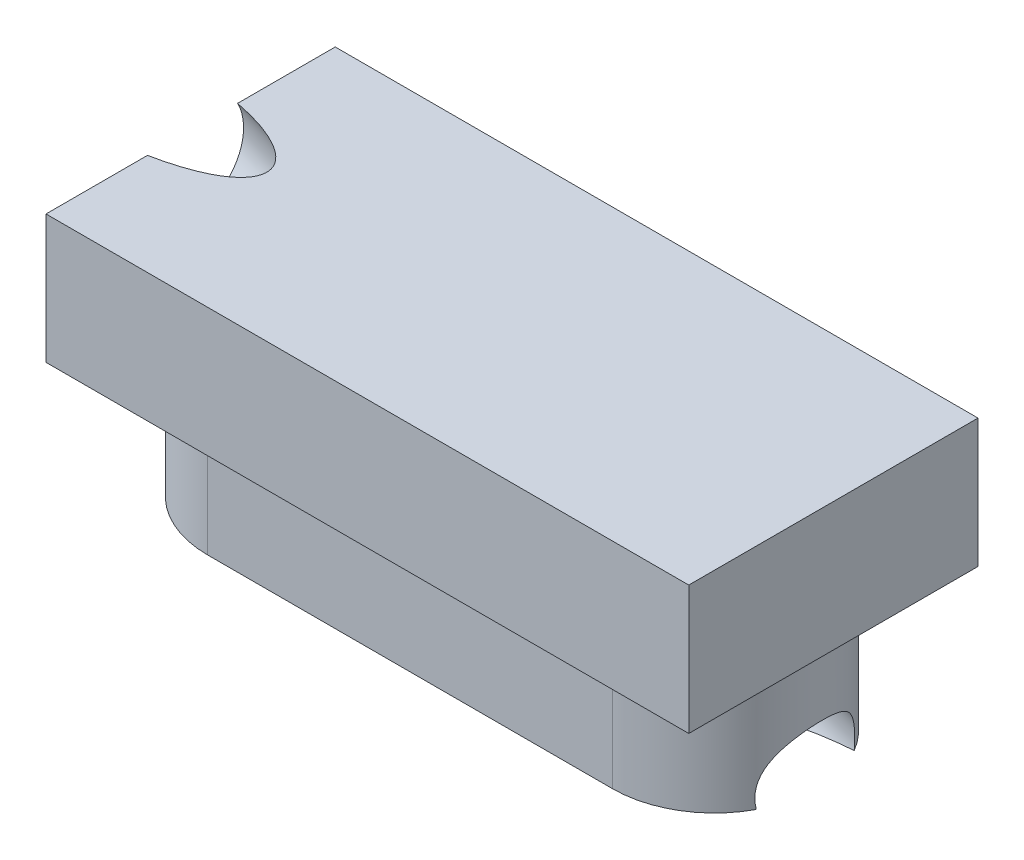
from build123d import *

# Parameters (mm, degrees)
SKETCH1_W           = 3.15
SKETCH1_H           = 1.5875
BOSS_EXTRUDE1_DEPTH = 1
SKETCH5_W           = 5
SKETCH5_H           = 2.25
BOSS_EXTRUDE2_DEPTH = 1
SKETCH4_2_R         = 0.396875


with BuildPart() as part:
    # Sketch1 → Boss-Extrude1 (new body)
    with BuildSketch(Plane(origin=(0, 0, 0), x_dir=(1, 0, 0), z_dir=(0, 1, 0))):
        with Locations((0, -0.047367461)):
            Rectangle(SKETCH1_W, SKETCH1_H)
        with BuildLine():
            Line((-1.575, -0.841117461), (-1.575, 0.746382539))
            ThreePointArc((-1.575, 0.746382539), (-2.36875, -0.047367461), (-1.575, -0.841117461))
        make_face()
        with BuildLine():
            ThreePointArc((1.575, -0.841117461), (2.36875, -0.047367461), (1.575, 0.746382539))
            Line((1.575, 0.746382539), (1.575, -0.841117461))
        make_face()
    extrude(amount=BOSS_EXTRUDE1_DEPTH)

    # Sketch5 → Boss-Extrude2 (add)
    with BuildSketch(Plane(origin=(0, 1, 0), x_dir=(1, 0, 0), z_dir=(0, 1, 0))):
        with Locations((0, -0.047367461)):
            Rectangle(SKETCH5_W, SKETCH5_H)
    extrude(amount=BOSS_EXTRUDE2_DEPTH)

    # Cut-Sweep4: sweep along a path in Sketch6
    with BuildLine(Plane.XY) as cut_sweep4_path:
        Line((2.5, 0), (-2.867631708, 1.95365817))
    # Sketch4_2 → Cut-Sweep4 (sweep, cut)
    with BuildSketch(Plane(origin=(2.5, 1, 0), x_dir=(0, 0, 1), z_dir=(-1, 0, 0))):
        with Locations((0.032314724, -1.006488934)):
            Circle(SKETCH4_2_R)
    sweep(path=cut_sweep4_path.line, mode=Mode.SUBTRACT)


solid = part.part
